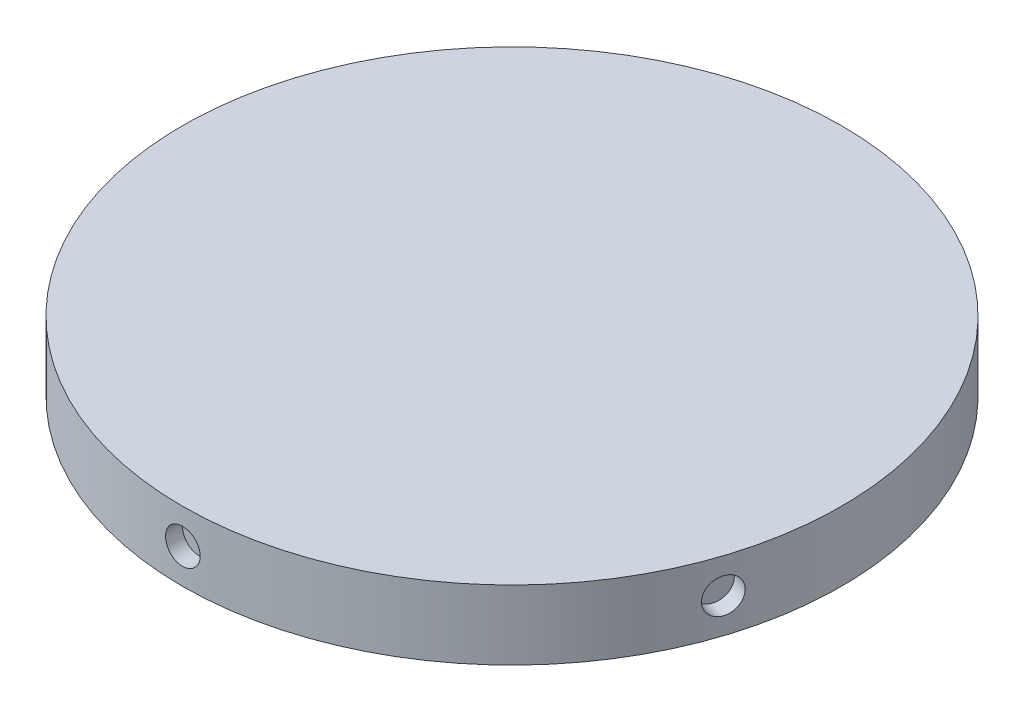
from build123d import *

# Parameters (mm, degrees)
SKETCH1_R           = 60.325
BOSS_EXTRUDE1_DEPTH = 12.7
SKETCH2_R           = 3.175
CUT_EXTRUDE1_DEPTH  = 19.05
CRVPATTERN1_COUNT   = 5


with BuildPart() as part:
    # Sketch1 → Boss-Extrude1 (new body)
    with BuildSketch(Plane(origin=(0, 0, 0), x_dir=(1, 0, 0), z_dir=(0, 1, 0))):
        with Locations(Location((0, 0, 0), (0, 0, 270))):
            Circle(SKETCH1_R)
    extrude(amount=BOSS_EXTRUDE1_DEPTH)

    # Sketch2 → Cut-Extrude1 (cut)
    with BuildSketch(Plane.XY.offset(76.2)):
        with Locations((0, 6.35)):
            Circle(SKETCH2_R)
    cut_extrude1 = extrude(amount=-CUT_EXTRUDE1_DEPTH, mode=Mode.SUBTRACT)

    # CrvPattern1: Cut-Extrude1 ×5 about axis
    crvpattern1_axis = Axis((0, 12.7, 0), (0, -1, 0))
    for i in range(1, CRVPATTERN1_COUNT):
        add(cut_extrude1.rotate(crvpattern1_axis, i * 360 / CRVPATTERN1_COUNT), mode=Mode.SUBTRACT)


solid = part.part
